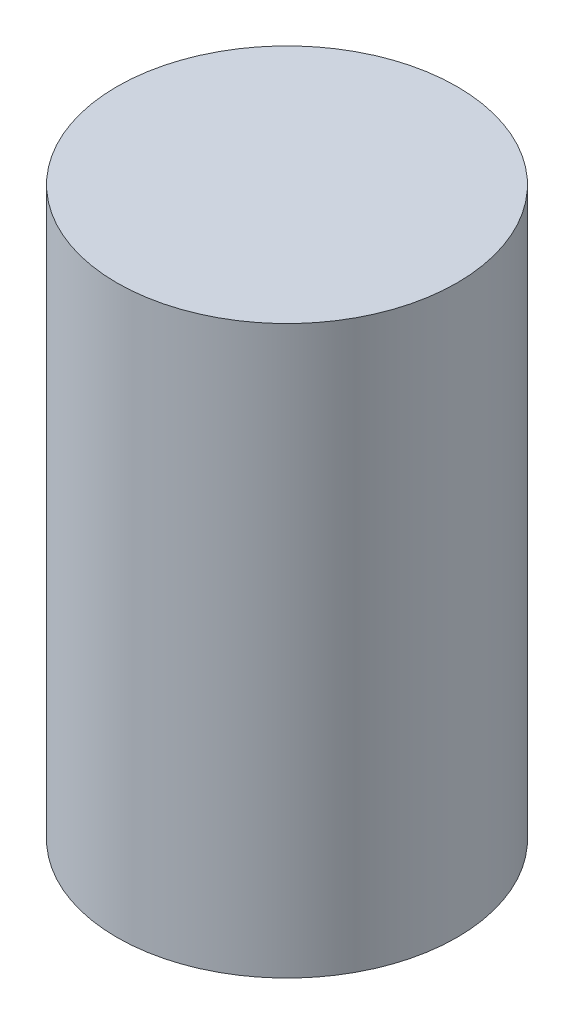
from build123d import *

# Parameters (mm, degrees)
SKIZZE1_R                       = 30
AUFSATZ_LINEAR_AUSTRAGEN1_DEPTH = 100


with BuildPart() as part:
    # Skizze1 → Aufsatz-Linear austragen1 (new body)
    with BuildSketch(Plane(origin=(0, 0, 0), x_dir=(1, 0, 0), z_dir=(0, 1, 0))):
        with Locations(Location((0, 0, 0), (0, 0, 270))):  # turned: the seam where the file's is
            Circle(SKIZZE1_R)
    extrude(amount=AUFSATZ_LINEAR_AUSTRAGEN1_DEPTH)


solid = part.part
